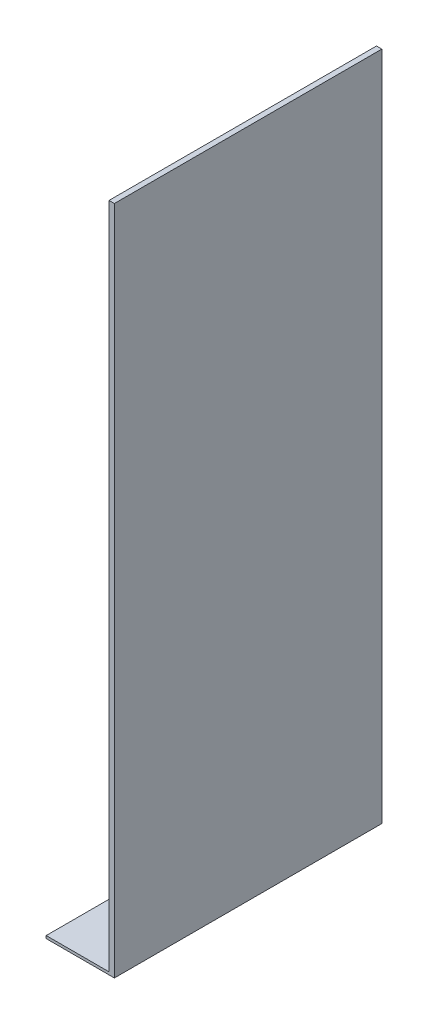
from build123d import *

# Parameters (mm, degrees)
SKETCH1_W           = 200
SKETCH1_H           = 501.6
BOSS_EXTRUDE1_DEPTH = 4
SKETCH2_W           = 200
SKETCH2_H           = 2
BOSS_EXTRUDE2_DEPTH = 47


with BuildPart() as part:
    # Sketch1 → Boss-Extrude1 (new body)
    with BuildSketch(Plane(origin=(0, 0, 0), x_dir=(0, 0, -1), z_dir=(1, 0, 0))):
        with Locations((-38.720930233, -147.020930233)):
            Rectangle(SKETCH1_W, SKETCH1_H)
    extrude(amount=BOSS_EXTRUDE1_DEPTH)

    # Sketch2 → Boss-Extrude2 (add)
    with BuildSketch(Plane.ZY):
        with Locations((38.720930233, -396.820930233)):
            Rectangle(SKETCH2_W, SKETCH2_H)
    extrude(amount=BOSS_EXTRUDE2_DEPTH)


solid = part.part
